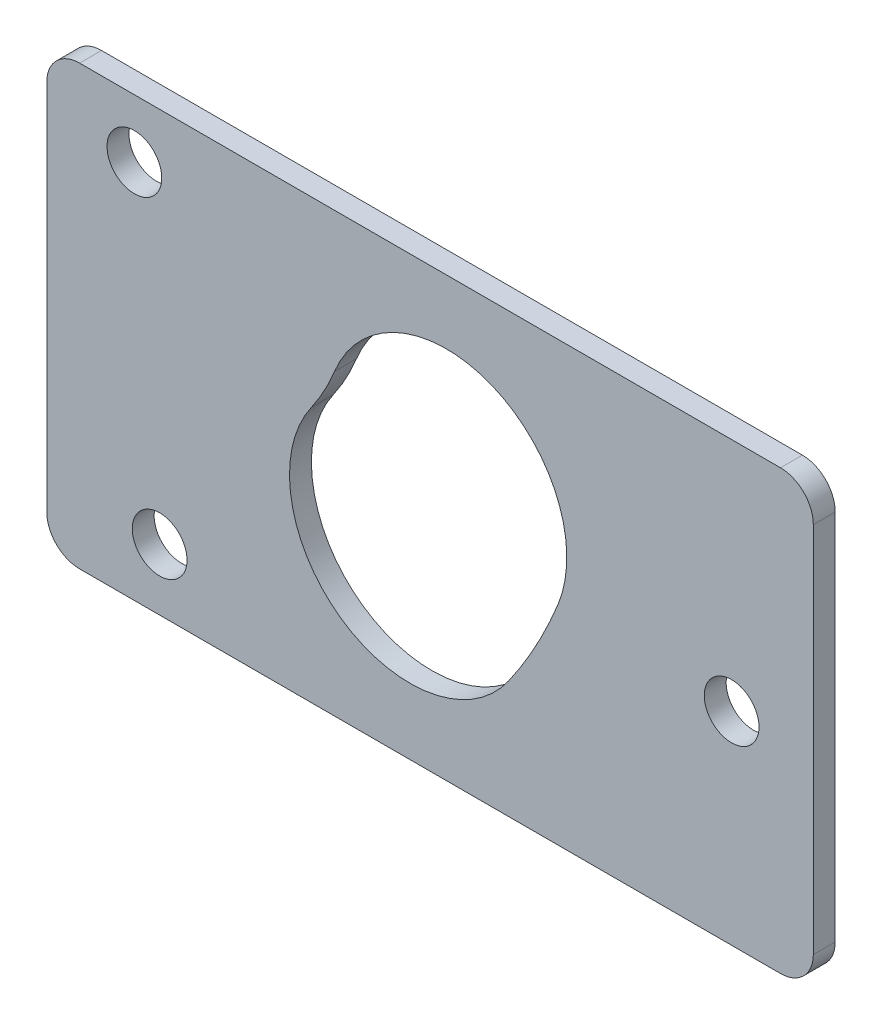
from build123d import *

# Parameters (mm, degrees)
SZKIC2_R                    = 2.5
DODANIE_WYCI_GNI_CIE3_DEPTH = 2


with BuildPart() as part:
    # Szkic2 → Dodanie-wyciągnięcie3 (new body)
    with BuildSketch(Plane.XY):
        with BuildLine():
            ThreePointArc((-35, -17), (-34.121320344, -19.121320344), (-32, -20))
            Line((-32, -20), (32, -20))
            ThreePointArc((32, -20), (34.121320344, -19.121320344), (35, -17))
            Line((35, -17), (35, 17))
            ThreePointArc((35, 17), (34.121320344, 19.121320344), (32, 20))
            Line((32, 20), (-32, 20))
            ThreePointArc((-32, 20), (-34.121320344, 19.121320344), (-35, 17))
            Line((-35, 17), (-35, -17))
        make_face()
        with Locations((-24.693752651, -14.408678002)):
            Circle(SZKIC2_R, mode=Mode.SUBTRACT)
        with BuildLine():
            ThreePointArc((11.684967283, -0.97190814), (9.665957804, -5.250643745), (7.175560187, -9.273316659))
            ThreePointArc((7.175560187, -9.273316659), (-8.144983036, -11.971641207), (-10.843307584, 3.348902015))
            ThreePointArc((-10.843307584, 3.348902015), (-9.665957804, 5.250643745), (-8.711459473, 7.273440584))
            ThreePointArc((-8.711459473, 7.273440584), (5.609428267, 13.3489796), (11.684967283, -0.97190814))
        make_face(mode=Mode.SUBTRACT)
        with Locations((27.540515543, -1.488970059)):
            Circle(SZKIC2_R, mode=Mode.SUBTRACT)
        with Locations((-27, 14.666666667)):
            Circle(SZKIC2_R, mode=Mode.SUBTRACT)
    extrude(amount=DODANIE_WYCI_GNI_CIE3_DEPTH)


solid = part.part
